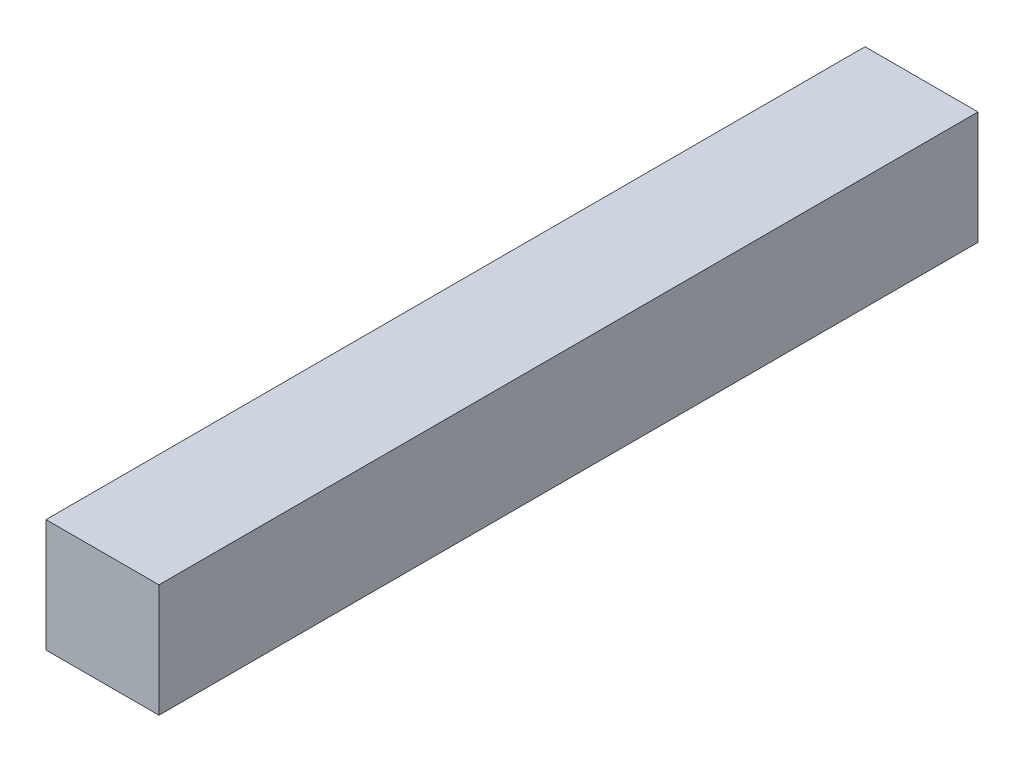
from build123d import *

# Parameters (mm, degrees)
SKETCH1_W           = 20
SKETCH1_H           = 145
BOSS_EXTRUDE1_DEPTH = 20


with BuildPart() as part:
    # Sketch1 → Boss-Extrude1 (new body)
    with BuildSketch(Plane(origin=(0, 0, 0), x_dir=(1, 0, 0), z_dir=(0, 1, 0))):
        with Locations((26.686746988, -34.284638554)):
            Rectangle(SKETCH1_W, SKETCH1_H)
    extrude(amount=BOSS_EXTRUDE1_DEPTH)


solid = part.part
